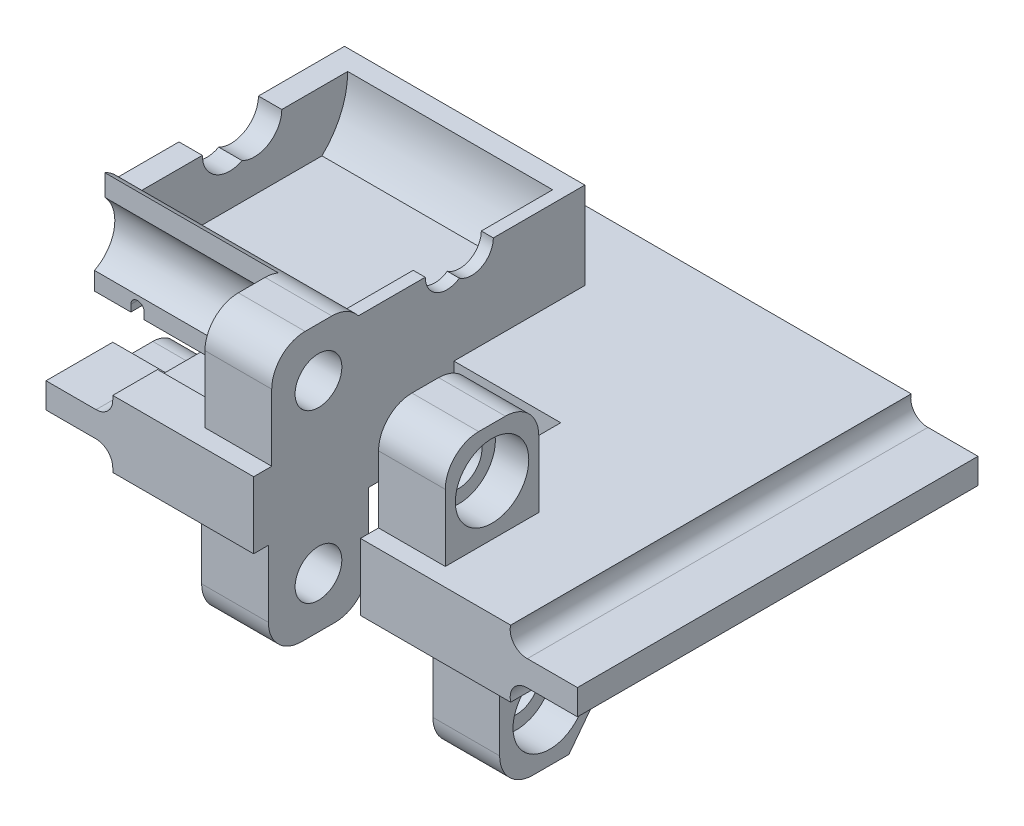
from build123d import *
from build123d.topology import SkipClean

# Parameters (mm, degrees)
EXTRUDE_1_DEPTH          = 60
CUT_EXTRUDE_1_DEPTH      = 17.3
SKETCH1_W                = 16
SKETCH1_H                = 30
CUT_EXTRUDE1_DEPTH       = 10
SKETCH2_R                = 3.5
BOSS_EXTRUDE1_DEPTH      = 10
SKETCH4_R                = 5.5
CUT_EXTRUDE4_DEPTH       = 5
SKETCH5_R                = 3.5
BOSS_EXTRUDE2_DEPTH      = 10
SKETCH6_R                = 5.5
CUT_EXTRUDE5_DEPTH       = 5
BOSS_EXTRUDE4_DEPTH      = 36
SKETCH8_W                = 1.8
SKETCH8_H                = 32.418049597
SKETCH8_W_2              = 3.5
SKETCH8_H_2              = 30.966699179
BOSS_EXTRUDE5_DEPTH      = 10
CUT_EXTRUDE6_DEPTH       = 10
CUT_EXTRUDE7_DEPTH       = 10
CUT_EXTRUDE9_DEPTH       = 10
CUT_EXTRUDE10_DEPTH      = 10
CUT_EXTRUDE10_DEPTH_BACK = 35
CUT_EXTRUDE8_DEPTH       = 24
CUT_EXTRUDE8_DEPTH_BACK  = 68.060525711
BOSS_EXTRUDE8_REACH      = 89.449
CUT_EXTRUDE12_DEPTH      = 30.7
CUT_EXTRUDE13_DEPTH      = 4.551723699
CUT_EXTRUDE14_DEPTH      = 14


with BuildPart() as part:
    # 스케치1 → 보스-돌출1 (new body)
    with BuildSketch(Plane.XY):
        with BuildLine():
            Line((29.8, 10), (-29.8, 10))
            Line((-29.8, 10), (-29.8, 9.4))
            ThreePointArc((-29.8, 9.4), (-30.532233047, 7.632233047), (-32.3, 6.9))
            Line((-32.3, 6.9), (-39.8, 6.9))
            Line((-39.8, 6.9), (-39.8, 3.1))
            Line((-39.8, 3.1), (-32.3, 3.1))
            ThreePointArc((-32.3, 3.1), (-30.532233047, 2.367766953), (-29.8, 0.6))
            Line((-29.8, 0.6), (-29.8, 0))
            Line((-29.8, 0), (29.8, 0))
            ThreePointArc((29.8, 0), (30.280633401, 2.170456935), (32.3, 3.1))
            Line((32.3, 3.1), (39.8, 3.1))
            Line((39.8, 3.1), (39.8, 6.9))
            Line((39.8, 6.9), (32.3, 6.9))
            ThreePointArc((32.3, 6.9), (30.280633401, 7.829543065), (29.8, 10))
        make_face()
    extrude(amount=EXTRUDE_1_DEPTH)

    # 스케치2 → 컷-돌출1 (cut)
    with BuildSketch(Plane.ZY.offset(39.8)):
        with BuildLine():
            Line((44, 4), (50, 4))
            Line((50, 4), (50, 8))
            Line((50, 8), (10, 8))
            Line((10, 8), (10, 4))
            Line((10, 4), (16, 4))
            ThreePointArc((16, 4), (18.828427125, 2.828427125), (20, 0))
            Line((20, 0), (40, 0))
            ThreePointArc((40, 0), (41.171572875, 2.828427125), (44, 4))
        make_face()
    extrude(amount=-CUT_EXTRUDE_1_DEPTH, mode=Mode.SUBTRACT)

    # Sketch1 → Cut-Extrude1 (cut)
    with BuildSketch(Plane(origin=(0, 10, 0), x_dir=(1, 0, 0), z_dir=(0, 1, 0))):
        with Locations((-0.7, -45)):
            Rectangle(SKETCH1_W, SKETCH1_H)
    extrude(amount=-CUT_EXTRUDE1_DEPTH, mode=Mode.SUBTRACT)

    # Sketch2 → Boss-Extrude1 (add)
    with BuildSketch(Plane.ZY.offset(-7.3)):
        with BuildLine():
            Line((57.29, 10), (43.29, 10))
            Line((43.29, 10), (43.29, 20))
            ThreePointArc((43.29, 20), (44.754466094, 23.535533906), (48.29, 25))
            Line((48.29, 25), (52.29, 25))
            ThreePointArc((52.29, 25), (55.825533906, 23.535533906), (57.29, 20))
            Line((57.29, 20), (57.29, 10))
        make_face()
        with Locations((50.29, 17.61)):
            Circle(SKETCH2_R, mode=Mode.SUBTRACT)
    boss_extrude1 = extrude(amount=-BOSS_EXTRUDE1_DEPTH)

    # Sketch4 → Cut-Extrude4 (cut)
    with BuildSketch(Plane(origin=(17.3, 0, 0), x_dir=(0, 0, -1), z_dir=(1, 0, 0))):
        with Locations((-50.29, 17.61)):
            Circle(SKETCH4_R)
    cut_extrude4 = extrude(amount=-CUT_EXTRUDE4_DEPTH, mode=Mode.SUBTRACT)

    # Mirror1: Boss-Extrude1, Cut-Extrude4 across plane
    add(boss_extrude1.mirror(Plane.ZY.offset(0.7)))
    add(cut_extrude4.mirror(Plane.ZY.offset(0.7)), mode=Mode.SUBTRACT)

    # Sketch5 → Boss-Extrude2 (add)
    with BuildSketch(Plane(origin=(-8.7, 0, 0), x_dir=(0, 0, -1), z_dir=(1, 0, 0))):
        with BuildLine():
            Line((-57.79, 0), (-42.79, 0))
            Line((-42.79, 0), (-42.79, -10))
            ThreePointArc((-42.79, -10), (-44.254466094, -13.535533906), (-47.79, -15))
            Line((-47.79, -15), (-52.79, -15))
            ThreePointArc((-52.79, -15), (-56.325533906, -13.535533906), (-57.79, -10))
            Line((-57.79, -10), (-57.79, 0))
        make_face()
        with Locations((-50.29, -7.39000045)):
            Circle(SKETCH5_R, mode=Mode.SUBTRACT)
    boss_extrude2 = extrude(amount=-BOSS_EXTRUDE2_DEPTH)

    # Sketch6 → Cut-Extrude5 (cut)
    with BuildSketch(Plane.ZY.offset(18.7)):
        with Locations((50.29, -7.39000045)):
            Circle(SKETCH6_R)
    cut_extrude5 = extrude(amount=-CUT_EXTRUDE5_DEPTH, mode=Mode.SUBTRACT)

    # Mirror2: Boss-Extrude2, Cut-Extrude5 across plane
    add(boss_extrude2.mirror(Plane(origin=(3.62, 0, 0), x_dir=(0, 0, 1), z_dir=(1, 0, 0))))
    add(cut_extrude5.mirror(Plane(origin=(3.62, 0, 0), x_dir=(0, 0, 1), z_dir=(1, 0, 0))), mode=Mode.SUBTRACT)

    # Sketch7 → Boss-Extrude4 (add)
    with BuildSketch(Plane(origin=(-8.7, 0, 0), x_dir=(0, 0, -1), z_dir=(1, 0, 0))):
        with BuildLine():
            Line((-17.261786151, 14), (-40.058213849, 14))
            ThreePointArc((-40.058213849, 14), (-41.99066638, 16.369643708), (-43.29, 19.137551985))
            Line((-43.29, 19.137551985), (-43.29, 10))
            Line((-43.29, 10), (-30, 10))
            Line((-30, 10), (-10.385441698, 10))
            Line((-10.385441698, 10), (-10.385441698, 23.025430584))
            Line((-10.385441698, 23.025430584), (-13.41, 23.025430584))
            ThreePointArc((-13.41, 23.025430584), (-14.413203205, 18.118938615), (-17.261786151, 14))
        make_face()
    extrude(amount=-BOSS_EXTRUDE4_DEPTH)

    # Sketch8 → Boss-Extrude5 (add)
    with BuildSketch(Plane(origin=(0, 23.025430584, 0), x_dir=(1, 0, 0), z_dir=(0, 1, 0))):
        with Locations((-9.6, -29.619024798)):
            Rectangle(SKETCH8_W, SKETCH8_H)
        with Locations((-42.95, -28.89334959)):
            Rectangle(SKETCH8_W_2, SKETCH8_H_2)
    extrude(amount=-BOSS_EXTRUDE5_DEPTH)

    # Sketch9 → Cut-Extrude6 (cut)
    with BuildSketch(Plane(origin=(-8.7, 0, 0), x_dir=(0, 0, -1), z_dir=(1, 0, 0))):
        with BuildLine():
            Line((-27.797320777, 23.025430584), (-24.097320777, 23.025430584))
            ThreePointArc((-24.097320777, 23.025430584), (-25.839010464, 25.904232418), (-29.197320777, 25.697508427))
            ThreePointArc((-29.197320777, 25.697508427), (-28.168518943, 24.533740897), (-27.797320777, 23.025430584))
        make_face()
        with BuildLine():
            ThreePointArc((-29.197320777, 20.353352741), (-25.839010464, 20.14662875), (-24.097320777, 23.025430584))
            Line((-24.097320777, 23.025430584), (-27.797320777, 23.025430584))
            ThreePointArc((-27.797320777, 23.025430584), (-28.168518943, 21.517120271), (-29.197320777, 20.353352741))
        make_face()
        with BuildLine():
            ThreePointArc((-27.797320777, 23.025430584), (-28.168518943, 24.533740897), (-29.197320777, 25.697508427))
            ThreePointArc((-29.197320777, 25.697508427), (-30.226122611, 24.533740897), (-30.597320777, 23.025430584))
            Line((-30.597320777, 23.025430584), (-27.797320777, 23.025430584))
        make_face()
        with BuildLine():
            ThreePointArc((-30.597320777, 23.025430584), (-30.226122611, 24.533740897), (-29.197320777, 25.697508427))
            ThreePointArc((-29.197320777, 25.697508427), (-32.55563109, 25.904232418), (-34.297320777, 23.025430584))
            Line((-34.297320777, 23.025430584), (-30.597320777, 23.025430584))
        make_face()
        with BuildLine():
            ThreePointArc((-34.297320777, 23.025430584), (-32.55563109, 20.14662875), (-29.197320777, 20.353352741))
            ThreePointArc((-29.197320777, 20.353352741), (-30.226122611, 21.517120271), (-30.597320777, 23.025430584))
            Line((-30.597320777, 23.025430584), (-34.297320777, 23.025430584))
        make_face()
        with BuildLine():
            ThreePointArc((-30.597320777, 23.025430584), (-30.226122611, 21.517120271), (-29.197320777, 20.353352741))
            ThreePointArc((-29.197320777, 20.353352741), (-28.168518943, 21.517120271), (-27.797320777, 23.025430584))
            Line((-27.797320777, 23.025430584), (-30.597320777, 23.025430584))
        make_face()
    extrude(amount=-CUT_EXTRUDE6_DEPTH, mode=Mode.SUBTRACT)

    # Sketch10 → Cut-Extrude7 (cut)
    with BuildSketch(Plane.ZY.offset(44.7)):
        with BuildLine():
            Line((26.981070438, 23.025430584), (31.481070438, 23.025430584))
            ThreePointArc((31.481070438, 23.025430584), (30.873562385, 25.173103744), (29.231070438, 26.684323859))
            ThreePointArc((29.231070438, 26.684323859), (27.588578491, 25.173103744), (26.981070438, 23.025430584))
        make_face()
        with BuildLine():
            Line((35.181070438, 23.025430584), (31.481070438, 23.025430584))
            ThreePointArc((31.481070438, 23.025430584), (30.873562385, 20.877757425), (29.231070438, 19.366537309))
            ThreePointArc((29.231070438, 19.366537309), (33.228743598, 19.532938637), (35.181070438, 23.025430584))
        make_face()
        with BuildLine():
            ThreePointArc((29.231070438, 26.684323859), (30.873562385, 25.173103744), (31.481070438, 23.025430584))
            Line((31.481070438, 23.025430584), (35.181070438, 23.025430584))
            ThreePointArc((35.181070438, 23.025430584), (33.228743598, 26.517922531), (29.231070438, 26.684323859))
        make_face()
        with BuildLine():
            ThreePointArc((29.231070438, 19.366537309), (30.873562385, 20.877757425), (31.481070438, 23.025430584))
            Line((31.481070438, 23.025430584), (26.981070438, 23.025430584))
            ThreePointArc((26.981070438, 23.025430584), (27.588578491, 20.877757425), (29.231070438, 19.366537309))
        make_face()
        with BuildLine():
            ThreePointArc((26.981070438, 23.025430584), (27.588578491, 25.173103744), (29.231070438, 26.684323859))
            ThreePointArc((29.231070438, 26.684323859), (25.233397279, 26.517922531), (23.281070438, 23.025430584))
            Line((23.281070438, 23.025430584), (26.981070438, 23.025430584))
        make_face()
        with BuildLine():
            ThreePointArc((23.281070438, 23.025430584), (25.233397279, 19.532938637), (29.231070438, 19.366537309))
            ThreePointArc((29.231070438, 19.366537309), (27.588578491, 20.877757425), (26.981070438, 23.025430584))
            Line((26.981070438, 23.025430584), (23.281070438, 23.025430584))
        make_face()
    extrude(amount=-CUT_EXTRUDE7_DEPTH, mode=Mode.SUBTRACT)

    # Sketch12 → Cut-Extrude9 (cut)
    with BuildSketch(Plane(origin=(25.94, 0, 0), x_dir=(0, 0, -1), z_dir=(1, 0, 0))):
        Polygon((-42.79, -8.93619037), (-47.402449947, -14.984957869), (-43.167493301, -15.543555396), (-40.889176965, -10), align=None)
    extrude(amount=-CUT_EXTRUDE9_DEPTH, mode=Mode.SUBTRACT)

    # Sketch13 → Cut-Extrude10 (cut, two sides)
    with BuildSketch(Plane.XY.offset(43.29)) as cut_extrude10_sk:
        with BuildLine():
            Line((-29.8, 10), (-23.780440028, 10))
            Line((-23.780440028, 10), (-23.780440028, 11.102878987))
            ThreePointArc((-23.780440028, 11.102878987), (-22.780440028, 12.102878987), (-21.780440028, 11.102878987))
            Line((-21.780440028, 11.102878987), (-21.780440028, 9))
            Line((-21.780440028, 9), (-30.475963693, 9))
            Line((-30.475963693, 9), (-29.8, 10))
        make_face()
    extrude(amount=CUT_EXTRUDE10_DEPTH, mode=Mode.SUBTRACT)
    extrude(cut_extrude10_sk.sketch, amount=-CUT_EXTRUDE10_DEPTH_BACK, mode=Mode.SUBTRACT)

    # Sketch11 → Cut-Extrude8 (cut, two sides)
    with BuildSketch(Plane.XY.offset(43.29)) as cut_extrude8_sk:
        with BuildLine():
            Line((-39.25, 10), (-39.25, 11))
            ThreePointArc((-39.25, 11), (-38.25, 12), (-37.25, 11))
            Line((-37.25, 11), (-37.25, 10))
            Line((-37.25, 10), (-39.25, 10))
        make_face()
    extrude(amount=CUT_EXTRUDE8_DEPTH, mode=Mode.SUBTRACT)
    extrude(cut_extrude8_sk.sketch, amount=-CUT_EXTRUDE8_DEPTH_BACK, mode=Mode.SUBTRACT)

    # Boss-Extrude8: up to this face of the body (flat: up to its plane)
    boss_extrude8_end = Plane(part.part.faces().sort_by_distance((-44.7, 16.071146892, 27.054729008))[0])
    # Sketch17 → Boss-Extrude8 (add, up to the picked face)
    with BuildSketch(Plane.ZY.offset(18.7), mode=Mode.PRIVATE) as boss_extrude8_sk1:
        with BuildLine():
            Line((43.29, 10), (47.841723699, 10))
            Line((47.841723699, 10), (47.841723699, 12.6849677))
            ThreePointArc((47.841723699, 12.6849677), (44.875969931, 16.641352279), (46.285947009, 21.380617939))
            Line((46.285947009, 21.380617939), (46.285947009, 24.58080469))
            ThreePointArc((46.285947009, 24.58080469), (44.10548898, 22.736762233), (43.29, 20))
            Line((43.29, 20), (43.29, 10))
        make_face()
    boss_extrude8_tool1 = split(extrude(boss_extrude8_sk1.sketch, amount=BOSS_EXTRUDE8_REACH, mode=Mode.PRIVATE), bisect_by=boss_extrude8_end, keep=Keep.BOTH, mode=Mode.PRIVATE)
    add(boss_extrude8_tool1.solids().sort_by(Axis((-18.7, 15.819122, 44.969973), (-1, 0, 0)))[0])

    # Sketch16 → Cut-Extrude12 (cut)
    with SkipClean():  # the faces are left unmerged after this step: merging them gives an invalid solid
        with BuildSketch(Plane.ZY.offset(10.5)):
            with BuildLine():
                Line((39.210033139, 14), (40.058213849, 14))
                ThreePointArc((40.058213849, 14), (42.906796795, 18.118938615), (43.91, 23.025430584))
                Line((43.91, 23.025430584), (41.137773768, 23.025430584))
                Line((41.137773768, 23.025430584), (39.210033139, 14))
            make_face()
        extrude(amount=CUT_EXTRUDE12_DEPTH, mode=Mode.SUBTRACT)

    # Sketch18 → Cut-Extrude13 (cut)
    with SkipClean():  # the faces are left unmerged after this step: merging them gives an invalid solid
        with BuildSketch(Plane(origin=(0, 0, 43.29), x_dir=(-1, 0, 0), z_dir=(0, 0, -1))):
            with BuildLine():
                Line((21.780440028, 11.102878987), (21.780440028, 10))
                Line((21.780440028, 10), (23.780440028, 10))
                Line((23.780440028, 10), (23.780440028, 11.102878987))
                ThreePointArc((23.780440028, 11.102878987), (22.780440028, 12.102878987), (21.780440028, 11.102878987))
            make_face()
        extrude(amount=-CUT_EXTRUDE13_DEPTH, mode=Mode.SUBTRACT)

    # Sketch19 → Cut-Extrude14 (cut)
    with SkipClean():  # the faces are left unmerged after this step: merging them gives an invalid solid
        with BuildSketch(Plane(origin=(0, 0, 43.29), x_dir=(-1, 0, 0), z_dir=(0, 0, -1))):
            with BuildLine():
                Line((37.25, 11), (37.25, 10))
                Line((37.25, 10), (39.25, 10))
                Line((39.25, 10), (39.25, 11))
                ThreePointArc((39.25, 11), (38.25, 12), (37.25, 11))
            make_face()
        extrude(amount=-CUT_EXTRUDE14_DEPTH, mode=Mode.SUBTRACT)


solid = part.part
